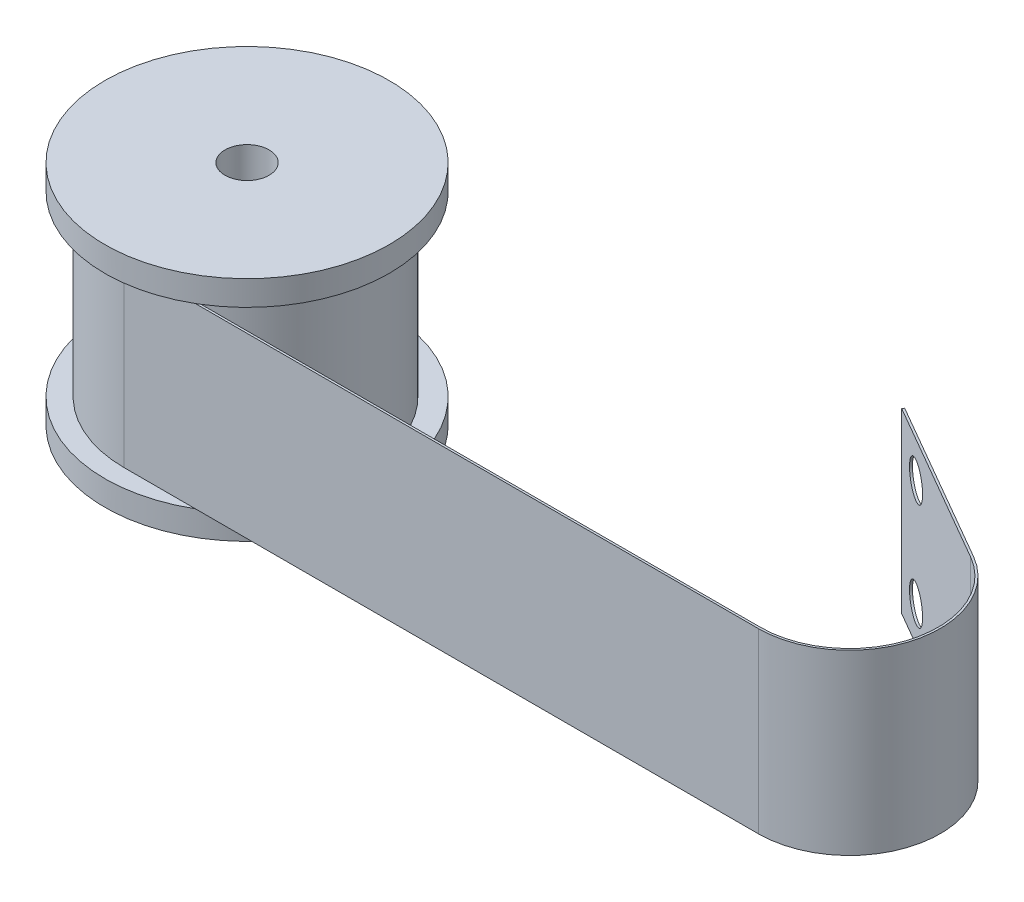
from build123d import *

# Parameters (mm, degrees)
EXTRUDE_THIN2_DEPTH = 25
SKETCH4_R           = 2.5
CUT_EXTRUDE1_DEPTH  = 0.3


with BuildPart() as part:
    # Sketch1 → Revolve1 (revolve)
    with BuildSketch(Plane.XY):
        Polygon((3.1, 16), (3.1, -16), (20, -16), (20, -12.5), (17, -12.5), (17, 12.5), (20, 12.5), (20, 16), align=None)
    revolve(axis=Axis((0, -1363.747655385, 0), (0, 1, 0)))

    # Sketch2 → Extrude-Thin2 (add)
    with BuildSketch(Plane(origin=(0, -12.5, 0), x_dir=(1, 0, 0), z_dir=(0, 1, 0))):
        with BuildLine():
            ThreePointArc((0, 17), (-17, 0), (0, -17))
            Line((0, -17), (89.2, -17))
            ThreePointArc((89.2, -17), (101.274072829, -7.735238064), (95.45, 6.325317547))
            Line((95.45, 6.325317547), (72.5003268, 19.575317547))
            Line((72.5003268, 19.575317547), (72.6503268, 19.835125168))
            Line((72.6503268, 19.835125168), (95.6, 6.585125168))
            ThreePointArc((95.6, 6.585125168), (101.563850577, -7.812883777), (89.2, -17.3))
            Line((89.2, -17.3), (0, -17.3))
            ThreePointArc((0, -17.3), (-17.3, 0), (0, 17.3))
            Line((0, 17.3), (0, 17))
        make_face()
    extrude(amount=EXTRUDE_THIN2_DEPTH)

    # Sketch4 → Cut-Extrude1 (cut)
    with BuildSketch(Plane(origin=(26.751442841, 0, -46.334858177), x_dir=(-0.866025404, 0, -0.5), z_dir=(0.5, 0, -0.866025404))):
        with Locations((-58.499466018, -7.5)):
            Circle(SKETCH4_R)
        with Locations((-58.499466018, 7.5)):
            Circle(SKETCH4_R)
    extrude(amount=-CUT_EXTRUDE1_DEPTH, mode=Mode.SUBTRACT)


solid = part.part
